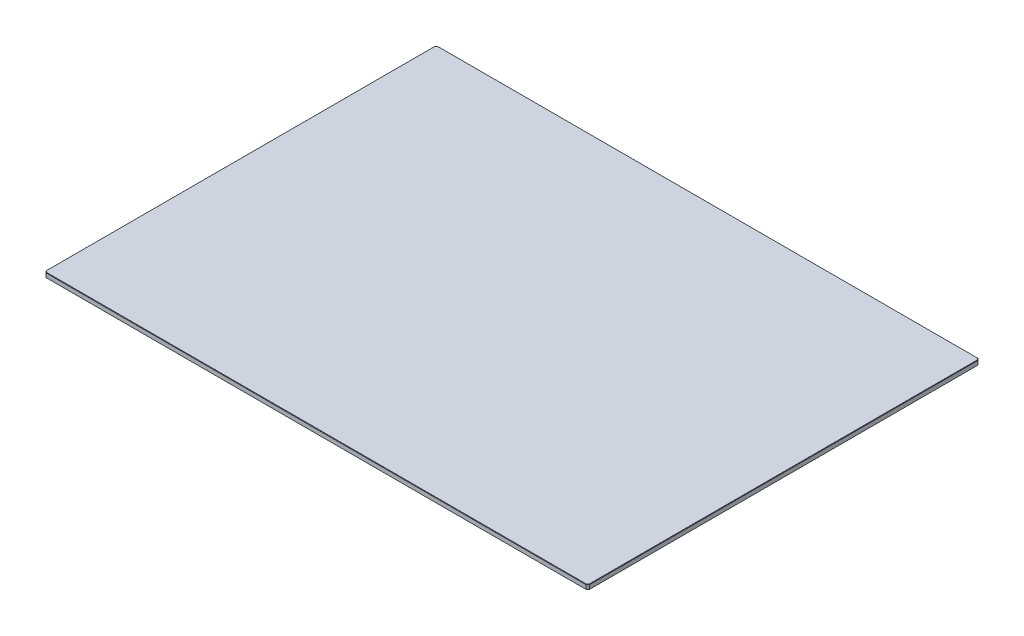
from build123d import *

# Parameters (mm, degrees)
BOSS_EXTRUDE1_DEPTH = 3.2
CHAMFER1_SIZE       = 0.254


with BuildPart() as part:
    # Sketch1 → Boss-Extrude1 (new body)
    with BuildSketch(Plane(origin=(0, 0, 0), x_dir=(1, 0, 0), z_dir=(0, 1, 0))):
        Polygon((0, 257.6125), (1.15, 258.7625), (357.625, 258.7625), (358.775, 257.6125), (358.775, 1.15), (357.625, 0), (1.15, 0), (0, 1.15), align=None)
    extrude(amount=BOSS_EXTRUDE1_DEPTH)

    # Chamfer1
    chamfer1_edges = [part.edges().sort_by_distance(p)[0] for p in [
        (179.3875, 3.2, 0),
        (0.575, 0, -0.575),
        (0, 0, -129.38125),
        (358.2, 3.2, -0.575),
        (358.775, 3.2, -129.38125),
        (358.2, 3.2, -258.1875),
        (179.3875, 3.2, -258.7625),
        (0.575, 3.2, -258.1875),
        (0, 3.2, -129.38125),
        (0.575, 3.2, -0.575),
        (0.575, 0, -258.1875),
        (179.3875, 0, -258.7625),
        (358.2, 0, -258.1875),
        (358.775, 0, -129.38125),
        (358.2, 0, -0.575),
        (179.3875, 0, 0),
    ]]
    chamfer(chamfer1_edges, length=CHAMFER1_SIZE)


solid = part.part
